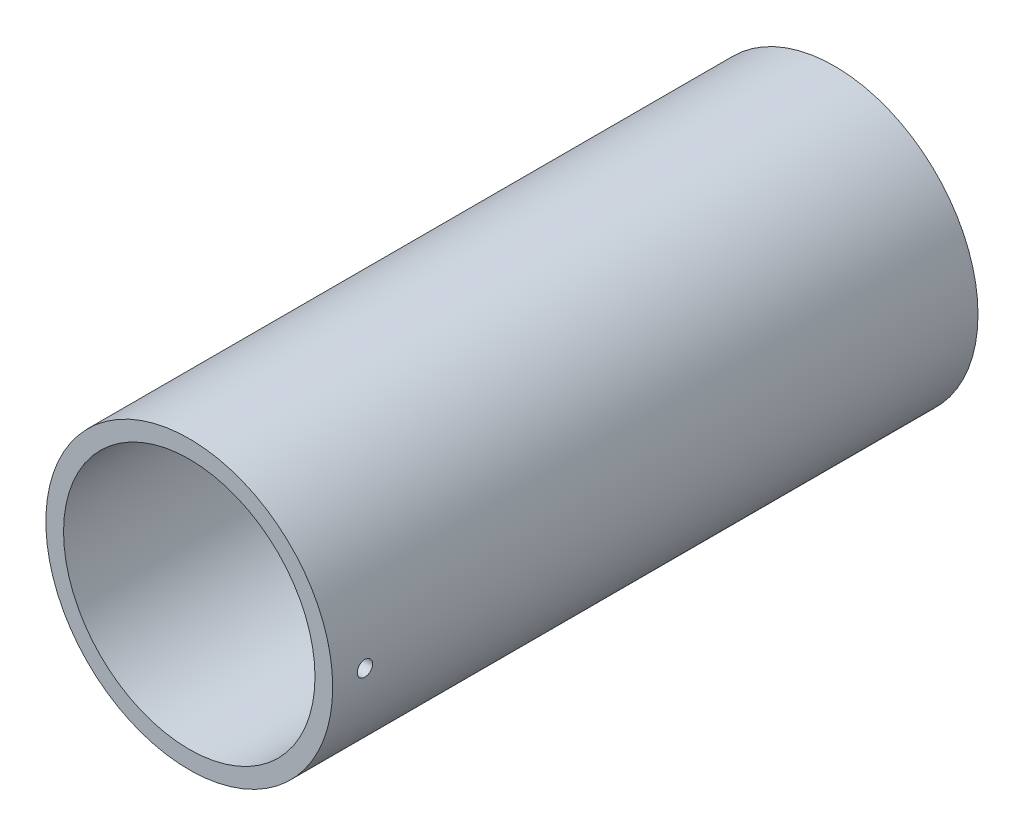
from build123d import *

# Parameters (mm, degrees)
SKETCH1_R           = 44.45
SKETCH1_R_2         = 38.9636
EXTRUDE_THIN1_DEPTH = 100
SKETCH2_W           = 2.38125
SKETCH2_H           = 44.45


with BuildPart() as part:
    # Sketch1 → Extrude-Thin1 (new body, symmetric)
    with BuildSketch(Plane.XY):
        Circle(SKETCH1_R)
        Circle(SKETCH1_R_2, mode=Mode.SUBTRACT)
    extrude(amount=EXTRUDE_THIN1_DEPTH, both=True)

    # Sketch2 → 3/16 (0.1875) Diameter Hole1 (revolve, cut)
    with BuildSketch(Plane(origin=(0, 0, 90), x_dir=(0, 0, 1), z_dir=(0, 1, 0))):
        with Locations((1.190625, 22.225)):
            Rectangle(SKETCH2_W, SKETCH2_H)
    revolve(axis=Axis((-6.35, 0, 90), (1, 0, 0)), mode=Mode.SUBTRACT)


solid = part.part
